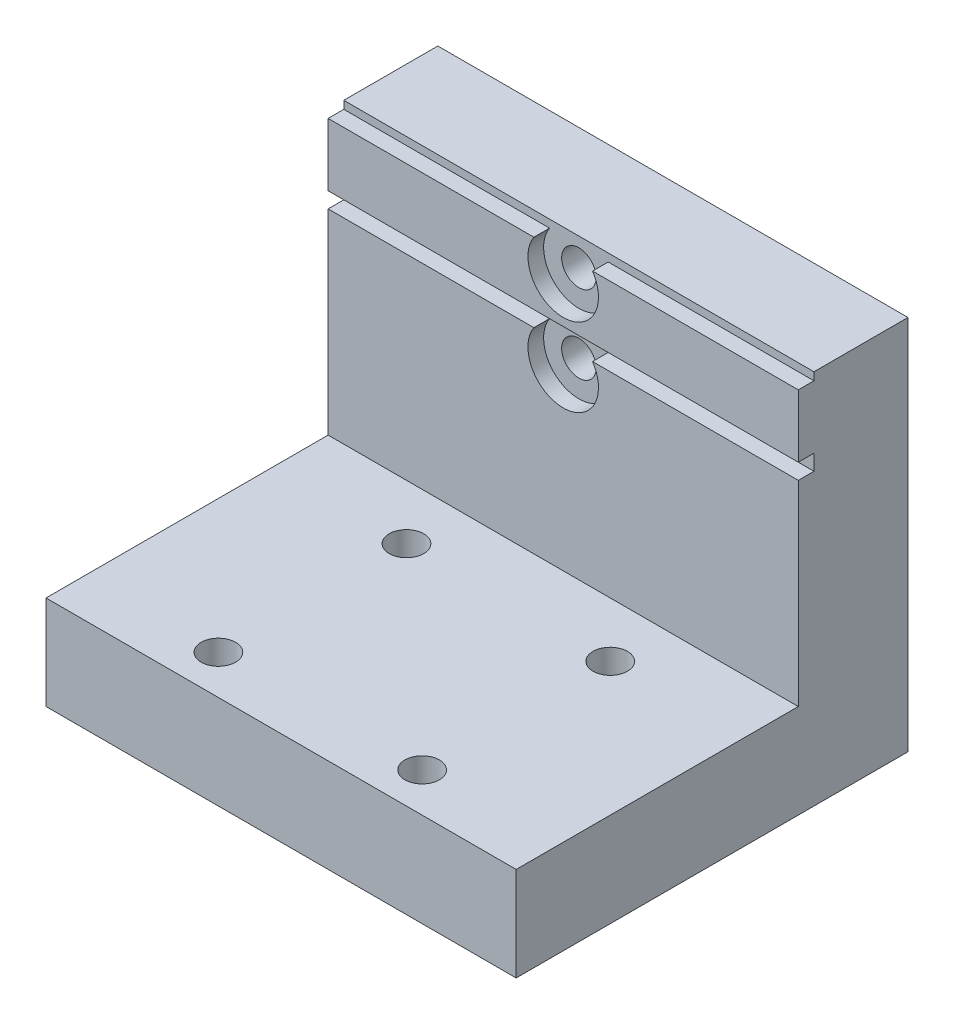
from build123d import *

# Parameters (mm, degrees)
RESSALTO_EXTRUS_O1_DEPTH = 15
ESBO_O3_R                = 1.1
CORTE_EXTRUS_O1_DEPTH    = 30
CORTE_EXTRUS_O8_DEPTH    = 1
ESBO_O16_R               = 1.1
CORTE_EXTRUS_O9_DEPTH    = 7
ESBO_O17_R               = 1.6
CORTE_EXTRUS_O10_DEPTH   = 3
ESBO_O18_R               = 1.6
CORTE_EXTRUS_O11_DEPTH   = 15
ESBO_O19_R               = 2.075
CORTE_EXTRUS_O12_DEPTH   = 4
ESBO_O20_R               = 2.2
CORTE_EXTRUS_O13_DEPTH   = 2


with BuildPart() as part:
    # Esboço1 → Ressalto-extrusão1 (new body, symmetric)
    with BuildSketch(Plane(origin=(0, 0, 0), x_dir=(0, 0, -1), z_dir=(1, 0, 0))):
        Polygon((0, 0), (0, -18), (-18, -18), (-18, -24), (7, -24), (7, 0), align=None)
    extrude(amount=RESSALTO_EXTRUS_O1_DEPTH, both=True)

    # Esboço3 → Corte-extrusão1 (cut)
    with BuildSketch(Plane.XZ.offset(18)):
        with Locations((-6.5, 15.5)):
            Circle(ESBO_O3_R)
        with Locations((6.5, 15.5)):
            Circle(ESBO_O3_R)
        with Locations((6.5, 3.5)):
            Circle(ESBO_O3_R)
        with Locations((-6.5, 3.5)):
            Circle(ESBO_O3_R)
    extrude(amount=CORTE_EXTRUS_O1_DEPTH, mode=Mode.SUBTRACT)

    # Esboço15 → Corte-extrusão8 (cut)
    with BuildSketch(Plane.XY):
        with BuildLine():
            Line((-1.870828693, -4.5), (-15, -4.5))
            Line((-15, -4.5), (-15, -5.5))
            Line((-15, -5.5), (-1.870828693, -5.5))
            ThreePointArc((-1.870828693, -5.5), (0, -9), (1.870828693, -5.5))
            Line((1.870828693, -5.5), (15, -5.5))
            Line((15, -5.5), (15, -4.5))
            Line((15, -4.5), (1.870828693, -4.5))
            Line((1.870828693, -4.5), (-1.870828693, -4.5))
        make_face()
        with BuildLine():
            Line((15, -0.5), (1.870828693, -0.5))
            ThreePointArc((1.870828693, -0.5), (0, -4), (-1.870828693, -0.5))
            Line((-1.870828693, -0.5), (-15, -0.5))
            Line((-15, -0.5), (-15, 0.5))
            Line((-15, 0.5), (-1.870828693, 0.5))
            Line((-1.870828693, 0.5), (1.870828693, 0.5))
            Line((1.870828693, 0.5), (15, 0.5))
            Line((15, 0.5), (15, -0.5))
        make_face()
    extrude(amount=-CORTE_EXTRUS_O8_DEPTH, mode=Mode.SUBTRACT)

    # Esboço16 → Corte-extrusão9 (cut)
    with BuildSketch(Plane.XY):
        with Locations((0, -1.75)):
            Circle(ESBO_O16_R)
        with Locations((0, -6.75)):
            Circle(ESBO_O16_R)
    extrude(amount=-CORTE_EXTRUS_O9_DEPTH, mode=Mode.SUBTRACT)

    # Esboço17 → Corte-extrusão10 (cut)
    with BuildSketch(Plane(origin=(0, 0, -7), x_dir=(-1, 0, 0), z_dir=(0, 0, -1))):
        with Locations((0, -1.75)):
            Circle(ESBO_O17_R)
        with Locations((0, -6.75)):
            Circle(ESBO_O17_R)
    extrude(amount=-CORTE_EXTRUS_O10_DEPTH, mode=Mode.SUBTRACT)

    # Esboço18 → Corte-extrusão11 (cut)
    with BuildSketch(Plane(origin=(0, 0, -7), x_dir=(-1, 0, 0), z_dir=(0, 0, -1))):
        with Locations((12.5, -21)):
            Circle(ESBO_O18_R)
        with Locations((-12.5, -21)):
            Circle(ESBO_O18_R)
    extrude(amount=-CORTE_EXTRUS_O11_DEPTH, mode=Mode.SUBTRACT)

    # Esboço19 → Corte-extrusão12 (cut)
    with BuildSketch(Plane(origin=(0, 0, -7), x_dir=(-1, 0, 0), z_dir=(0, 0, -1))):
        with Locations((12.5, -21)):
            Circle(ESBO_O19_R)
        with Locations((-12.5, -21)):
            Circle(ESBO_O19_R)
    extrude(amount=-CORTE_EXTRUS_O12_DEPTH, mode=Mode.SUBTRACT)

    # Esboço20 → Corte-extrusão13 (cut)
    with BuildSketch(Plane.XZ.offset(24)):
        with Locations((-6.5, 15.5)):
            Circle(ESBO_O20_R)
        with Locations((6.5, 15.5)):
            Circle(ESBO_O20_R)
        with Locations((6.5, 3.5)):
            Circle(ESBO_O20_R)
        with Locations((-6.5, 3.5)):
            Circle(ESBO_O20_R)
    extrude(amount=-CORTE_EXTRUS_O13_DEPTH, mode=Mode.SUBTRACT)


solid = part.part
